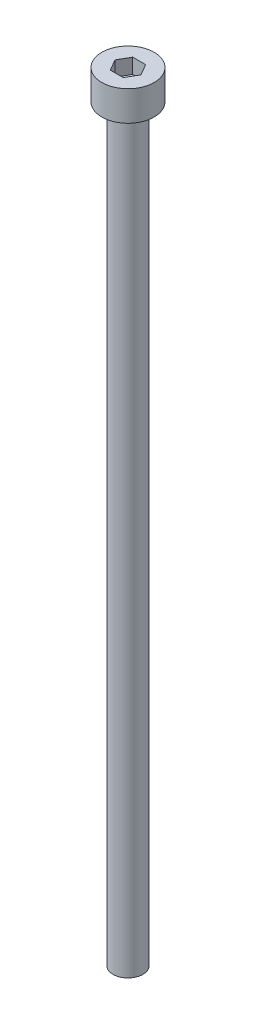
from build123d import *

# Parameters (mm, degrees)
SKETCH_1_R            = 3.5
EXTRUDE_246_DEPTH     = 4
CUT_EXTRUDE_376_DEPTH = 2
SKETCH_3_R            = 2
EXTRUDE_477_DEPTH     = 100


with BuildPart() as part:
    # 草图1 → Extrude 246 (new body)
    with BuildSketch(Plane(origin=(0, 0, 0), x_dir=(1, 0, 0), z_dir=(0, 1, 0))):
        Circle(SKETCH_1_R)
    extrude(amount=EXTRUDE_246_DEPTH)

    # 草图2 → Cut-Extrude 376 (cut)
    with BuildSketch(Plane(origin=(0, 4, 0), x_dir=(1, 0, 0), z_dir=(0, 1, 0))):
        Polygon((1.732050808, 0), (0.866025404, 1.5), (-0.866025404, 1.5), (-1.732050808, 0), (-0.866025404, -1.5), (0.866025404, -1.5), align=None)
    extrude(amount=-CUT_EXTRUDE_376_DEPTH, mode=Mode.SUBTRACT)

    # 草图3 → Extrude 477 (add)
    with BuildSketch(Plane.XZ):
        Circle(SKETCH_3_R)
    extrude(amount=EXTRUDE_477_DEPTH)


solid = part.part
